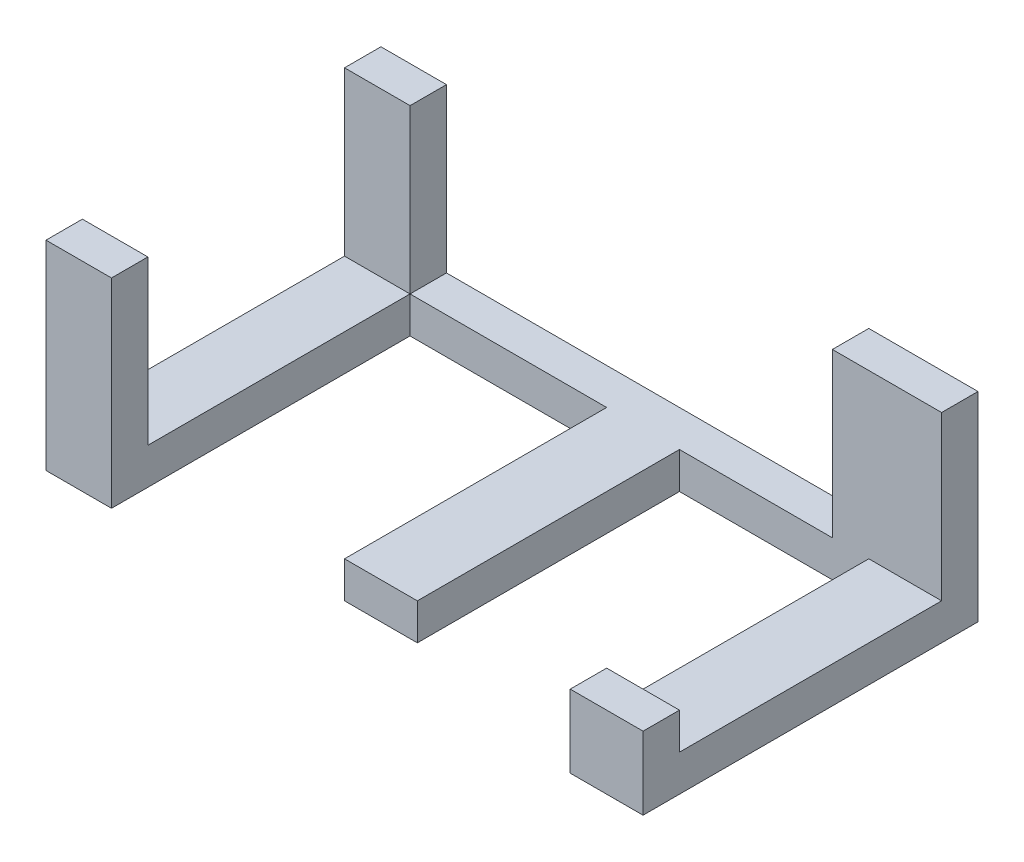
from build123d import *

# Parameters (mm, degrees)
CROQUIS1_W              = 82
CROQUIS1_H              = 5
SALIENTE_EXTRUIR1_DEPTH = 5
CROQUIS2_W              = 15
CROQUIS2_H              = 5
CROQUIS2_W_2            = 9
SALIENTE_EXTRUIR2_DEPTH = 22.4
CROQUIS3_W              = 8.993517989
CROQUIS3_H              = 5
CROQUIS3_W_2            = 10
SALIENTE_EXTRUIR3_DEPTH = 36
CROQUIS4_W              = 8.993517989
CROQUIS4_H              = 27.4
CROQUIS4_W_2            = 10
CROQUIS4_H_2            = 10
SALIENTE_EXTRUIR4_DEPTH = 5


with BuildPart() as part:
    # Croquis1 → Saliente-Extruir1 (new body)
    with BuildSketch(Plane.XY):
        with Locations((-17.772529993, -25.951946472)):
            Rectangle(CROQUIS1_W, CROQUIS1_H)
    extrude(amount=SALIENTE_EXTRUIR1_DEPTH)

    # Croquis2 → Saliente-Extruir2 (add)
    with BuildSketch(Plane(origin=(0, -23.451946472, 0), x_dir=(1, 0, 0), z_dir=(0, 1, 0))):
        with Locations((15.727470007, -2.5)):
            Rectangle(CROQUIS2_W, CROQUIS2_H)
        with Locations((-54.272529993, -2.5)):
            Rectangle(CROQUIS2_W_2, CROQUIS2_H)
    extrude(amount=SALIENTE_EXTRUIR2_DEPTH)

    # Croquis3 → Saliente-Extruir3 (add)
    with BuildSketch(Plane.XY.offset(5)):
        with Locations((-54.275770999, -25.951946472)):
            Rectangle(CROQUIS3_W, CROQUIS3_H)
        with Locations((-17.772529993, -25.951946472)):
            Rectangle(CROQUIS3_W_2, CROQUIS3_H)
        with Locations((18.227470007, -25.951946472)):
            Rectangle(CROQUIS3_W_2, CROQUIS3_H)
    extrude(amount=SALIENTE_EXTRUIR3_DEPTH)

    # Croquis4 → Saliente-Extruir4 (add)
    with BuildSketch(Plane.XY.offset(41)):
        with Locations((-54.275770999, -14.751946472)):
            Rectangle(CROQUIS4_W, CROQUIS4_H)
        with Locations((18.227470007, -23.451946472)):
            Rectangle(CROQUIS4_W_2, CROQUIS4_H_2)
    extrude(amount=SALIENTE_EXTRUIR4_DEPTH)


solid = part.part
